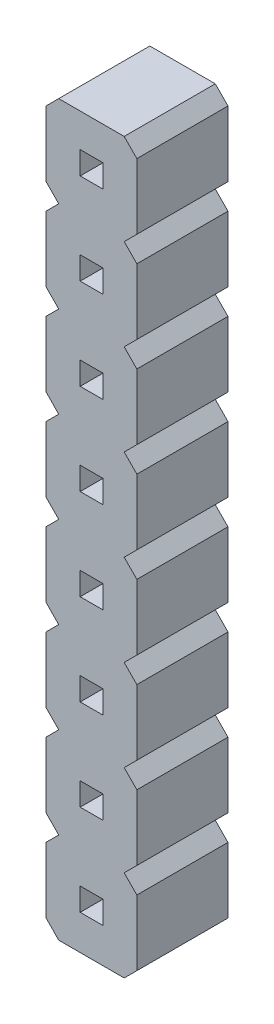
from build123d import *

# Parameters (mm, degrees)
PIN_DRAWING_W       = 0.636
PIN_DRAWING_H       = 0.636
BOSS_EXTRUDE1_DEPTH = 2.54


with BuildPart() as part:
    # pin_drawing → Boss-Extrude1 (new body)
    with BuildSketch(Plane.XY):
        Polygon((-0.014377737, 2.079116284), (-0.014377737, 0.25314904), (0.339175653, -0.107330326), (-0.014377737, -0.460883716), (-0.014377737, -2.28685096), (0.339175653, -2.647330326), (2.164719162, -2.647330326), (2.518272553, -2.293776935), (2.518272553, -0.46648), (2.164719162, -0.107330326), (2.518272553, 0.246223065), (2.518272553, 2.07352), (2.164719162, 2.432669674), (2.518272553, 2.786223065), (2.518272553, 4.61352), (2.164719162, 4.972669674), (2.518272553, 5.326223065), (2.518272553, 7.15352), (2.164719162, 7.512669674), (2.518272553, 7.866223065), (2.518272553, 9.69352), (2.164719162, 10.052669674), (2.518272553, 10.406223065), (2.518272553, 12.23352), (2.164719162, 12.592669674), (2.518272553, 12.946223065), (2.518272553, 14.77352), (2.164719162, 15.132669674), (2.518272553, 15.486223065), (2.518272553, 17.31352), (2.164719162, 17.672669674), (0.339175653, 17.672669674), (-0.014377737, 17.319116284), (-0.014377737, 15.49314904), (0.339175653, 15.132669674), (-0.014377737, 14.779116284), (-0.014377737, 12.95314904), (0.339175653, 12.592669674), (-0.014377737, 12.239116284), (-0.014377737, 10.41314904), (0.339175653, 10.052669674), (-0.014377737, 9.699116284), (-0.014377737, 7.87314904), (0.339175653, 7.512669674), (-0.014377737, 7.159116284), (-0.014377737, 5.33314904), (0.339175653, 4.972669674), (-0.014377737, 4.619116284), (-0.014377737, 2.79314904), (0.339175653, 2.432669674), align=None)
        with Locations((1.256122263, -1.357330326)):
            Rectangle(PIN_DRAWING_W, PIN_DRAWING_H, mode=Mode.SUBTRACT)
        with Locations((1.256122263, 1.182669674)):
            Rectangle(PIN_DRAWING_W, PIN_DRAWING_H, mode=Mode.SUBTRACT)
        with Locations((1.256122263, 3.722669674)):
            Rectangle(PIN_DRAWING_W, PIN_DRAWING_H, mode=Mode.SUBTRACT)
        with Locations((1.256122263, 6.262669674)):
            Rectangle(PIN_DRAWING_W, PIN_DRAWING_H, mode=Mode.SUBTRACT)
        with Locations((1.256122263, 8.802669674)):
            Rectangle(PIN_DRAWING_W, PIN_DRAWING_H, mode=Mode.SUBTRACT)
        with Locations((1.256122263, 11.342669674)):
            Rectangle(PIN_DRAWING_W, PIN_DRAWING_H, mode=Mode.SUBTRACT)
        with Locations((1.256122263, 13.882669674)):
            Rectangle(PIN_DRAWING_W, PIN_DRAWING_H, mode=Mode.SUBTRACT)
        with Locations((1.256122263, 16.422669674)):
            Rectangle(PIN_DRAWING_W, PIN_DRAWING_H, mode=Mode.SUBTRACT)
    extrude(amount=BOSS_EXTRUDE1_DEPTH)


solid = part.part
